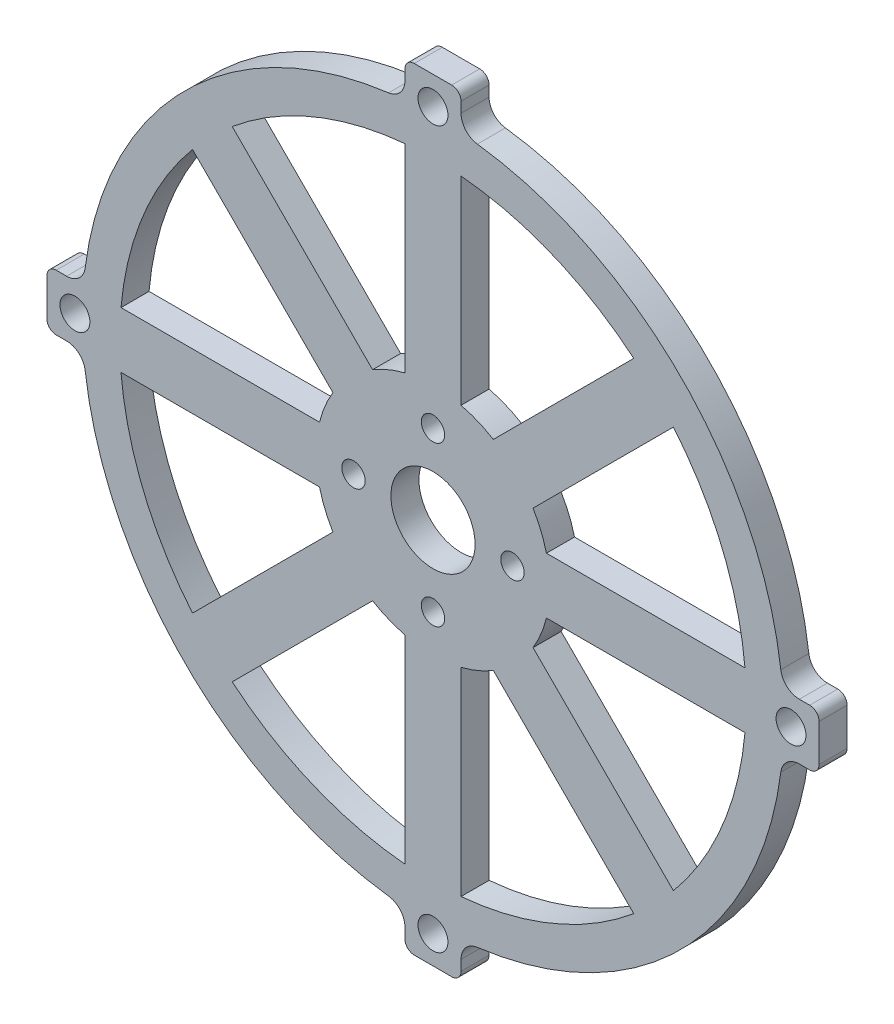
from build123d import *

# Parameters (mm, degrees)
SKETCH_1_R          = 1.6
EXTRUDE_1_DEPTH     = 3
SKETCH_3_R          = 4.5
SKETCH_3_R_2        = 1.25
CUT_EXTRUDE_1_DEPTH = 4
CUT_EXTRUDE_2_DEPTH = 4
FILLET_1_R          = 1


with BuildPart() as part:
    # ｽｹｯﾁ1 → ﾎﾞｽ - 押し出し1 (new body)
    with BuildSketch(Plane.XY):
        with BuildLine():
            Line((-3, -39.182266397), (-3, -41.291643997))
            Line((-3, -41.291643997), (3, -41.291643997))
            Line((3, -41.291643997), (3, -39.182266397))
            ThreePointArc((3, -39.182266397), (3.498945518, -37.860587373), (4.746835443, -37.198354174))
            ThreePointArc((4.746835443, -37.198354174), (26.516504294, -26.516504294), (37.198354174, -4.746835443))
            ThreePointArc((37.198354174, -4.746835443), (37.860587373, -3.498945518), (39.182266397, -3))
            Line((39.182266397, -3), (41.291643997, -3))
            Line((41.291643997, -3), (41.291643997, 3))
            Line((41.291643997, 3), (39.182266397, 3))
            ThreePointArc((39.182266397, 3), (37.860587373, 3.498945518), (37.198354174, 4.746835443))
            ThreePointArc((37.198354174, 4.746835443), (26.516504294, 26.516504294), (4.746835443, 37.198354174))
            ThreePointArc((4.746835443, 37.198354174), (3.498945518, 37.860587373), (3, 39.182266397))
            Line((3, 39.182266397), (3, 41.291643997))
            Line((3, 41.291643997), (-3, 41.291643997))
            Line((-3, 41.291643997), (-3, 39.182266397))
            ThreePointArc((-3, 39.182266397), (-3.498945518, 37.860587373), (-4.746835443, 37.198354174))
            ThreePointArc((-4.746835443, 37.198354174), (-26.516504294, 26.516504294), (-37.198354174, 4.746835443))
            ThreePointArc((-37.198354174, 4.746835443), (-37.860587373, 3.498945518), (-39.182266397, 3))
            Line((-39.182266397, 3), (-41.291643997, 3))
            Line((-41.291643997, 3), (-41.291643997, -3))
            Line((-41.291643997, -3), (-39.182266397, -3))
            ThreePointArc((-39.182266397, -3), (-37.860587373, -3.498945518), (-37.198354174, -4.746835443))
            ThreePointArc((-37.198354174, -4.746835443), (-26.516504294, -26.516504294), (-4.746835443, -37.198354174))
            ThreePointArc((-4.746835443, -37.198354174), (-3.498945518, -37.860587373), (-3, -39.182266397))
        make_face()
        with Locations((-38.291643997, 0)):
            Circle(SKETCH_1_R, mode=Mode.SUBTRACT)
        with Locations((0, -38.291643997)):
            Circle(SKETCH_1_R, mode=Mode.SUBTRACT)
        with Locations((0, 38.291643997)):
            Circle(SKETCH_1_R, mode=Mode.SUBTRACT)
        with Locations((38.291643997, 0)):
            Circle(SKETCH_1_R, mode=Mode.SUBTRACT)
    extrude(amount=EXTRUDE_1_DEPTH)

    # ｽｹｯﾁ3 → ｶｯﾄ - 押し出し1 (cut, through all)
    with BuildSketch(Plane.XY.offset(3)):
        Circle(SKETCH_3_R)
        with Locations((0, 8.5)):
            Circle(SKETCH_3_R_2)
        with Locations((8.5, 0)):
            Circle(SKETCH_3_R_2)
        with Locations((0, -8.5)):
            Circle(SKETCH_3_R_2)
        with Locations((-8.5, 0)):
            Circle(SKETCH_3_R_2)
    extrude(amount=-CUT_EXTRUDE_1_DEPTH, mode=Mode.SUBTRACT)

    # ｽｹｯﾁ4 → ｶｯﾄ - 押し出し2 (cut, through all)
    with BuildSketch(Plane.XY.offset(3)):
        with BuildLine():
            Line((-3, 33.365401241), (-3, 12.1346611))
            ThreePointArc((-3, 12.1346611), (-4.783542905, 11.548494156), (-6.459180807, 10.701821494))
            Line((-6.459180807, 10.701821494), (-21.471581131, 25.714221818))
            ThreePointArc((-21.471581131, 25.714221818), (-12.819894984, 30.949964339), (-3, 33.365401241))
        make_face()
        with BuildLine():
            Line((3, 33.365401241), (3, 12.1346611))
            ThreePointArc((3, 12.1346611), (4.783542905, 11.548494156), (6.459180807, 10.701821494))
            Line((6.459180807, 10.701821494), (21.471581131, 25.714221818))
            ThreePointArc((21.471581131, 25.714221818), (12.819894984, 30.949964339), (3, 33.365401241))
        make_face()
        with BuildLine():
            Line((33.365401241, 3), (12.1346611, 3))
            ThreePointArc((12.1346611, 3), (11.548494156, 4.783542905), (10.701821494, 6.459180807))
            Line((10.701821494, 6.459180807), (25.714221818, 21.471581131))
            ThreePointArc((25.714221818, 21.471581131), (30.949964339, 12.819894984), (33.365401241, 3))
        make_face()
        with BuildLine():
            Line((33.365401241, -3), (12.1346611, -3))
            ThreePointArc((12.1346611, -3), (11.548494156, -4.783542905), (10.701821494, -6.459180807))
            Line((10.701821494, -6.459180807), (25.714221818, -21.471581131))
            ThreePointArc((25.714221818, -21.471581131), (30.949964339, -12.819894984), (33.365401241, -3))
        make_face()
        with BuildLine():
            Line((3, -33.365401241), (3, -12.1346611))
            ThreePointArc((3, -12.1346611), (4.783542905, -11.548494156), (6.459180807, -10.701821494))
            Line((6.459180807, -10.701821494), (21.471581131, -25.714221818))
            ThreePointArc((21.471581131, -25.714221818), (12.819894984, -30.949964339), (3, -33.365401241))
        make_face()
        with BuildLine():
            Line((-3, -33.365401241), (-3, -12.1346611))
            ThreePointArc((-3, -12.1346611), (-4.783542905, -11.548494156), (-6.459180807, -10.701821494))
            Line((-6.459180807, -10.701821494), (-21.471581131, -25.714221818))
            ThreePointArc((-21.471581131, -25.714221818), (-12.819894984, -30.949964339), (-3, -33.365401241))
        make_face()
        with BuildLine():
            Line((-33.365401241, -3), (-12.1346611, -3))
            ThreePointArc((-12.1346611, -3), (-11.548494156, -4.783542905), (-10.701821494, -6.459180807))
            Line((-10.701821494, -6.459180807), (-25.714221818, -21.471581131))
            ThreePointArc((-25.714221818, -21.471581131), (-30.949964339, -12.819894984), (-33.365401241, -3))
        make_face()
        with BuildLine():
            Line((-33.365401241, 3), (-12.1346611, 3))
            ThreePointArc((-12.1346611, 3), (-11.548494156, 4.783542905), (-10.701821494, 6.459180807))
            Line((-10.701821494, 6.459180807), (-25.714221818, 21.471581131))
            ThreePointArc((-25.714221818, 21.471581131), (-30.949964339, 12.819894984), (-33.365401241, 3))
        make_face()
    extrude(amount=-CUT_EXTRUDE_2_DEPTH, mode=Mode.SUBTRACT)

    # ﾌｨﾚｯﾄ1
    fillet_1_edges = [part.edges().sort_by_distance(p)[0] for p in [
        (-41.291643997, -3, 1.5),
        (-41.291643997, 3, 1.5),
        (-3, 41.291643997, 1.5),
        (3, 41.291643997, 1.5),
        (41.291643997, 3, 1.5),
        (41.291643997, -3, 1.5),
        (3, -41.291643997, 1.5),
        (-3, -41.291643997, 1.5),
    ]]
    fillet(fillet_1_edges, radius=FILLET_1_R)


solid = part.part
